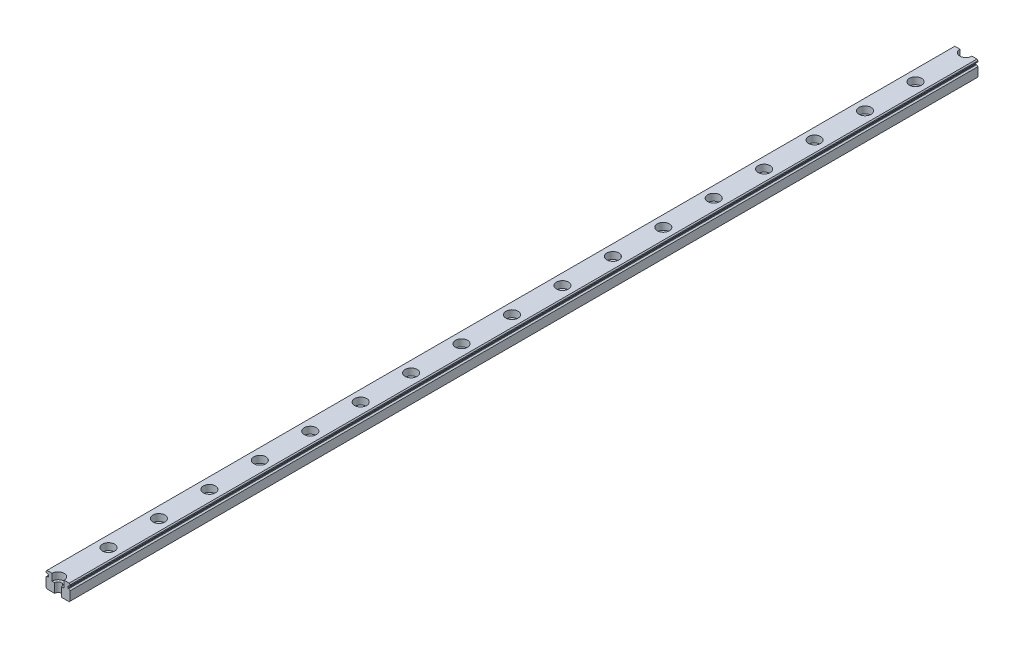
from build123d import *

# Parameters (mm, degrees)
SKETCH_1_W                = 12
SKETCH_1_H                = 8
EXTRUDE_1_DEPTH           = 225
CUT_EXTRUDE_1_DEPTH       = 451
CHAMFER_1_SIZE            = 0.5
HOLE_WIZARD_3_D           = 3.4
HOLE_WIZARD_3_CBORE_D     = 6
HOLE_WIZARD_3_CBORE_DEPTH = 3.4


with BuildPart() as part:
    # 草图1 → 凸台-拉伸1 (new body, symmetric)
    with BuildSketch(Plane.XY):
        Rectangle(SKETCH_1_W, SKETCH_1_H)
    extrude(amount=EXTRUDE_1_DEPTH, both=True)

    # 草图2 → 切除-拉伸1 (cut, through all)
    with BuildSketch(Plane(origin=(0, 0, -225), x_dir=(-1, 0, 0), z_dir=(0, 0, -1))):
        Polygon((5.2, 2.6), (4.8, 2.6), (4.8, 1.4), (5.2, 1.4), (6, 1), (6, 3), align=None)
    cut_extrude_1 = extrude(amount=-CUT_EXTRUDE_1_DEPTH, mode=Mode.SUBTRACT)

    # 镜向1: 切除-拉伸1 across plane
    add(cut_extrude_1.mirror(Plane(origin=(0, 0, 0), x_dir=(0, 0, 1), z_dir=(1, 0, 0))), mode=Mode.SUBTRACT)

    # 倒角1
    chamfer_1_edges = [part.edges().sort_by_distance(p)[0] for p in [
        (6, -4, 0),
        (-6, -4, 0),
        (-6, 4, 0),
        (6, 4, 0),
    ]]
    chamfer(chamfer_1_edges, length=CHAMFER_1_SIZE)

    # 打孔尺寸(%根据)内六角圆柱头螺钉的类型3 (through all)
    with Locations(Plane(origin=(0, 4, 0), x_dir=(1, 0, 0), z_dir=(0, 1, 0))):
        with Locations((0, 125), (0, 100), (0, 75), (0, 50), (0, 25), (0, 0), (0, -25), (0, -50), (0, -75), (0, -100), (0, -125), (0, 150), (0, 175), (0, 200), (0, -150), (0, -175), (0, -200), (0, -225), (0, 225)):
            CounterBoreHole(HOLE_WIZARD_3_D / 2, HOLE_WIZARD_3_CBORE_D / 2, HOLE_WIZARD_3_CBORE_DEPTH)


solid = part.part
